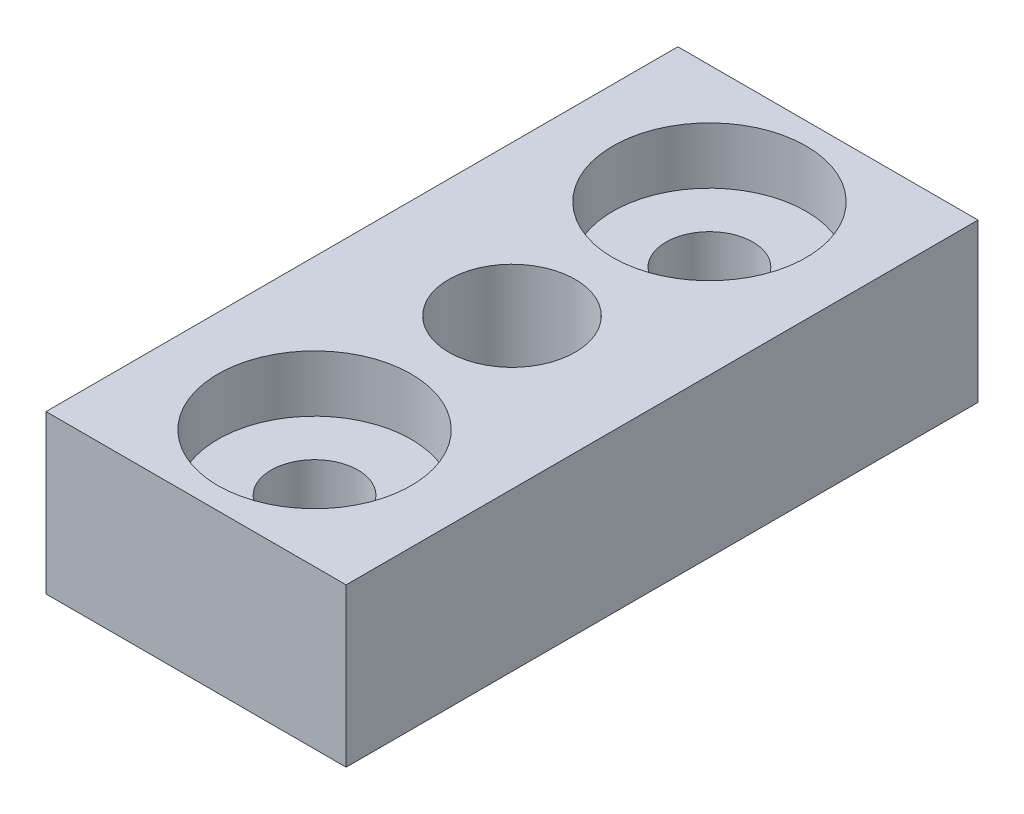
from build123d import *

# Parameters (mm, degrees)
SKETCH1_W                               = 19
SKETCH1_H                               = 40
SKETCH1_R                               = 4
BOSS_EXTRUDE1_DEPTH                     = 10
CBORE_FOR_M5_HEX_HEAD_BOLT1_D           = 5.5
CBORE_FOR_M5_HEX_HEAD_BOLT1_DEPTH       = 10
CBORE_FOR_M5_HEX_HEAD_BOLT1_CBORE_D     = 12.24
CBORE_FOR_M5_HEX_HEAD_BOLT1_CBORE_DEPTH = 3.58


with BuildPart() as part:
    # Sketch1 → Boss-Extrude1 (new body)
    with BuildSketch(Plane(origin=(0, 0, 0), x_dir=(1, 0, 0), z_dir=(0, 1, 0))):
        Rectangle(SKETCH1_W, SKETCH1_H)
        Circle(SKETCH1_R, mode=Mode.SUBTRACT)
    extrude(amount=BOSS_EXTRUDE1_DEPTH)

    # CBORE for M5 Hex Head Bolt1
    with Locations(Plane(origin=(0, 10, 0), x_dir=(1, 0, 0), z_dir=(0, 1, 0))):
        with Locations((0, 12.5), (0, -12.5)):
            CounterBoreHole(CBORE_FOR_M5_HEX_HEAD_BOLT1_D / 2, CBORE_FOR_M5_HEX_HEAD_BOLT1_CBORE_D / 2, CBORE_FOR_M5_HEX_HEAD_BOLT1_CBORE_DEPTH, depth=CBORE_FOR_M5_HEX_HEAD_BOLT1_DEPTH)


solid = part.part
